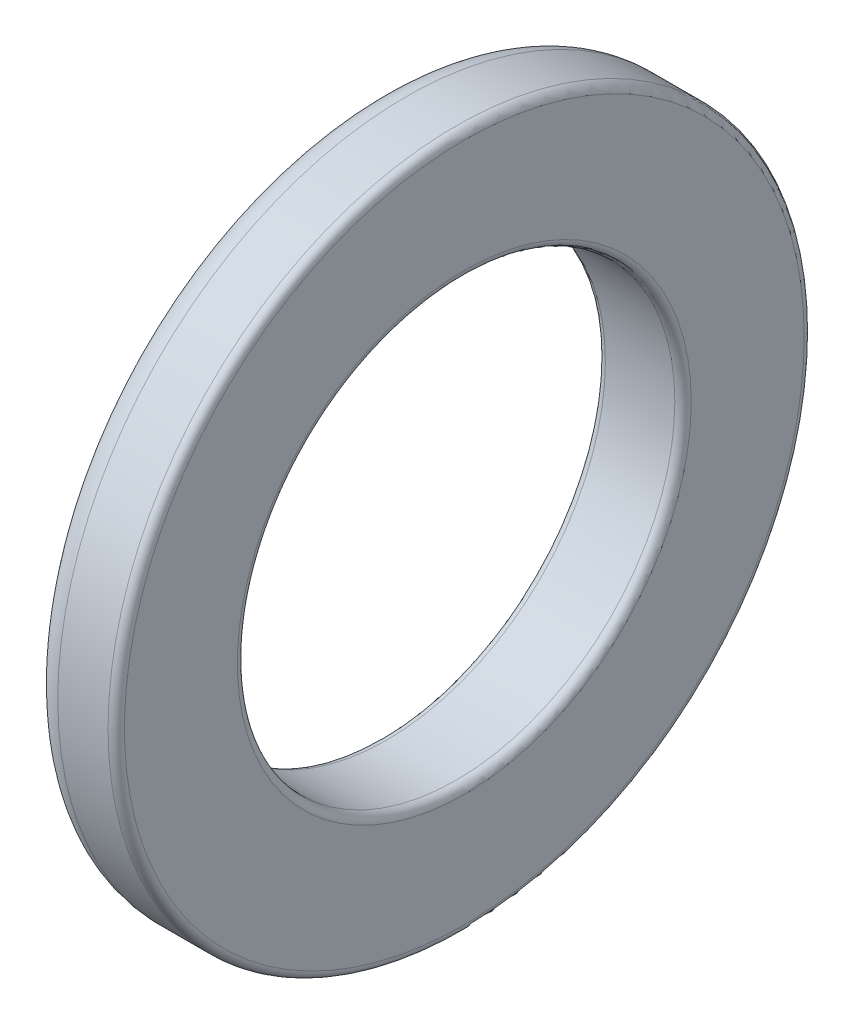
from build123d import *

# Parameters (mm, degrees)
SKETCH1_R           = 6.365
SKETCH1_R_2         = 4
BOSS_EXTRUDE1_DEPTH = 1.57
FILLET1_R           = 0.15
FILLET2_R           = 0.15
FILLET3_R           = 0.5


with BuildPart() as part:
    # Sketch1 → Boss-Extrude1 (new body)
    with BuildSketch(Plane(origin=(0, 0, 0), x_dir=(0, 0, -1), z_dir=(1, 0, 0))):
        Circle(SKETCH1_R)
        Circle(SKETCH1_R_2, mode=Mode.SUBTRACT)
    extrude(amount=BOSS_EXTRUDE1_DEPTH)

    # Fillet1
    fillet1_edges = [part.edges().sort_by_distance(p)[0] for p in [
        (1.57, 0, 6.365),
        (1.57, 0, 4),
    ]]
    fillet(fillet1_edges, radius=FILLET1_R)

    # Fillet2
    fillet2_edges = [part.edges().sort_by_distance(p)[0] for p in [
        (0, 0, 4),
    ]]
    fillet(fillet2_edges, radius=FILLET2_R)

    # Fillet3
    fillet3_edges = [part.edges().sort_by_distance(p)[0] for p in [
        (0, 0, 6.365),
    ]]
    fillet(fillet3_edges, radius=FILLET3_R)


solid = part.part
